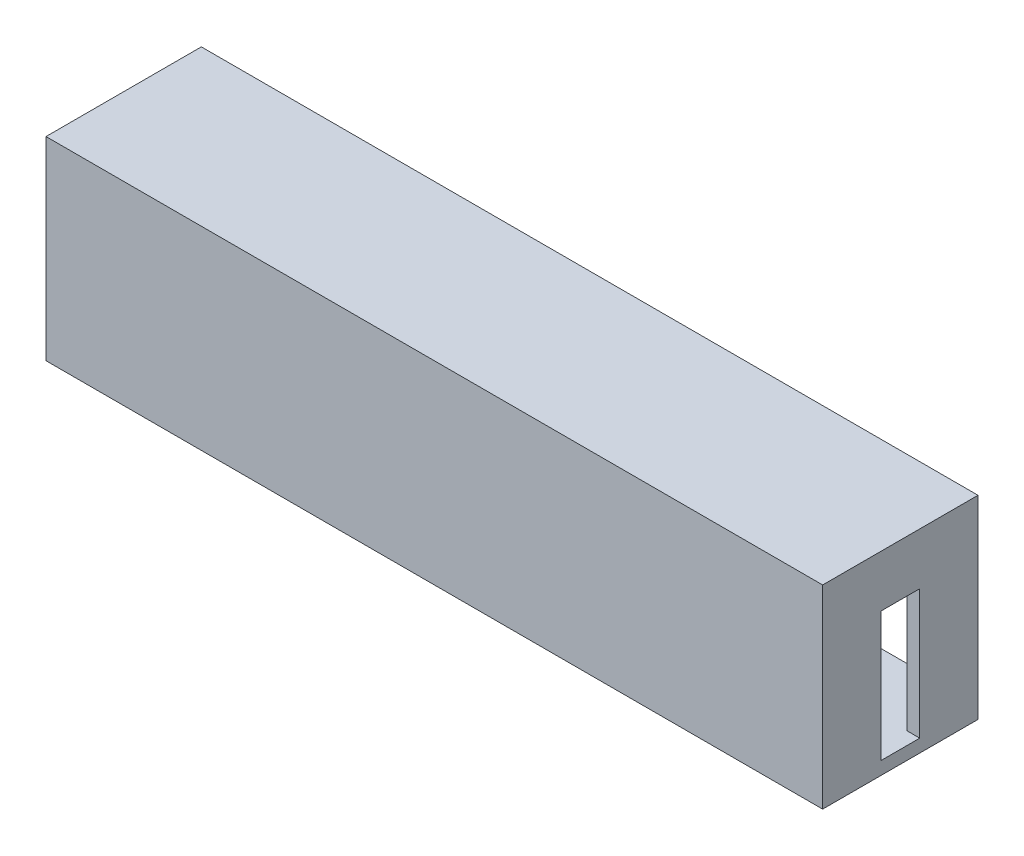
from build123d import *

# Parameters (mm, degrees)
SKETCH1_W           = 12000
SKETCH1_H           = 3000
SKETCH1_W_2         = 11600
SKETCH1_H_2         = 2600
BOSS_EXTRUDE1_DEPTH = 2400
SKETCH2_W           = 12000
SKETCH2_H           = 3000
BOSS_EXTRUDE2_DEPTH = 200
SKETCH3_W           = 11600
SKETCH3_H           = 60
BOSS_EXTRUDE3_DEPTH = 700
SKETCH4_W           = 11600
SKETCH4_H           = 40
BOSS_EXTRUDE4_DEPTH = 400
SKETCH5_W           = 600
SKETCH5_H           = 2000
CUT_EXTRUDE1_DEPTH  = 14169
SKETCH6_R           = 140
SKETCH6_R_2         = 90
BOSS_EXTRUDE5_DEPTH = 11662


with BuildPart() as part:
    # Sketch1 → Boss-Extrude1 (new body)
    with BuildSketch(Plane.XY):
        with Locations((6000, -1500)):
            Rectangle(SKETCH1_W, SKETCH1_H)
        with Locations((6000, -1500)):
            Rectangle(SKETCH1_W_2, SKETCH1_H_2, mode=Mode.SUBTRACT)
    extrude(amount=BOSS_EXTRUDE1_DEPTH)

    # Sketch2 → Boss-Extrude2 (add)
    with BuildSketch(Plane.XY.offset(2400)):
        with Locations((6000, -1500)):
            Rectangle(SKETCH2_W, SKETCH2_H)
    extrude(amount=-BOSS_EXTRUDE2_DEPTH)

    # Sketch3 → Boss-Extrude3 (add)
    with BuildSketch(Plane(origin=(0, 0, 2200), x_dir=(-1, 0, 0), z_dir=(0, 0, -1))):
        with Locations((-6000, -2150)):
            Rectangle(SKETCH3_W, SKETCH3_H)
    extrude(amount=BOSS_EXTRUDE3_DEPTH)

    # Sketch4 → Boss-Extrude4 (add)
    with BuildSketch(Plane(origin=(0, 0, 2200), x_dir=(-1, 0, 0), z_dir=(0, 0, -1))):
        with Locations((-6000, -1620)):
            Rectangle(SKETCH4_W, SKETCH4_H)
        with Locations((-6000, -1220)):
            Rectangle(SKETCH4_W, SKETCH4_H)
        with Locations((-6000, -820)):
            Rectangle(SKETCH4_W, SKETCH4_H)
    extrude(amount=BOSS_EXTRUDE4_DEPTH)

    # Sketch5 → Cut-Extrude1 (cut)
    with BuildSketch(Plane(origin=(12000, 0, 0), x_dir=(0, 0, -1), z_dir=(1, 0, 0))):
        with Locations((-1200, -1800)):
            Rectangle(SKETCH5_W, SKETCH5_H)
    extrude(amount=-CUT_EXTRUDE1_DEPTH, mode=Mode.SUBTRACT)

    # Sketch6 → Boss-Extrude5 (add)
    with BuildSketch(Plane(origin=(200, 0, 0), x_dir=(0, 0, -1), z_dir=(1, 0, 0))):
        with Locations((-1200, -400)):
            Circle(SKETCH6_R)
        with Locations((-1200, -400)):
            Circle(SKETCH6_R_2, mode=Mode.SUBTRACT)
    extrude(amount=BOSS_EXTRUDE5_DEPTH)


solid = part.part
